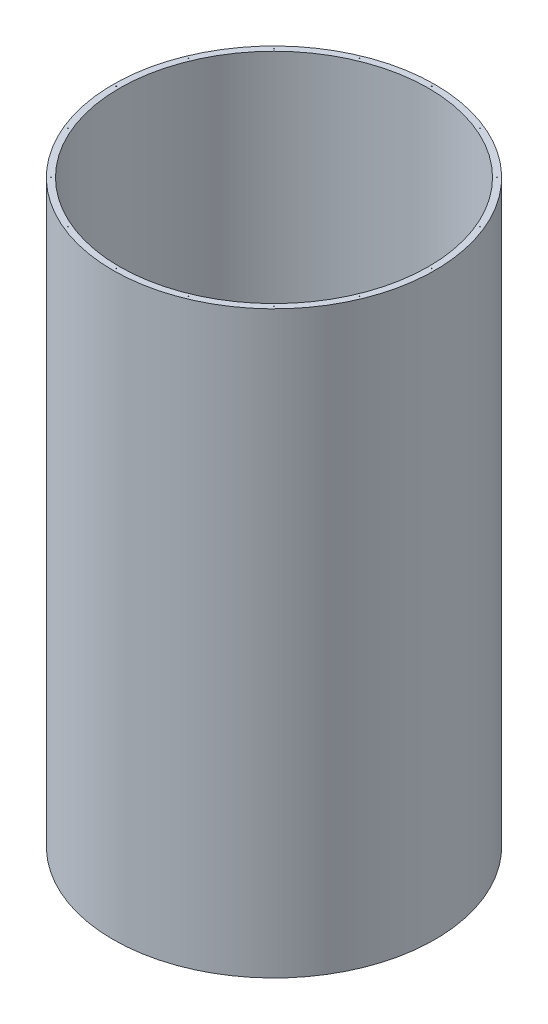
from build123d import *

# Parameters (mm, degrees)
SKETCH1_R           = 1250
SKETCH1_R_2         = 1200.000000046
BOSS_EXTRUDE1_DEPTH = 4500
SKETCH2_R           = 3.175
CUT_EXTRUDE1_DEPTH  = 12.7


with BuildPart() as part:
    # Sketch1 → Boss-Extrude1 (new body)
    with BuildSketch(Plane(origin=(0, 0, 0), x_dir=(1, 0, 0), z_dir=(0, 1, 0))):
        Circle(SKETCH1_R)
        Circle(SKETCH1_R_2, mode=Mode.SUBTRACT)
    extrude(amount=BOSS_EXTRUDE1_DEPTH)

    # Sketch2 → Cut-Extrude1 (cut)
    with BuildSketch(Plane(origin=(0, 4500, 0), x_dir=(1, 0, 0), z_dir=(0, 1, 0))):
        with Locations((-1225, 0)):
            Circle(SKETCH2_R)
        with Locations((-1131.752427326, 468.787204647)):
            Circle(SKETCH2_R)
        with Locations((-866.205806954, 866.205806954)):
            Circle(SKETCH2_R)
        with Locations((-468.787204647, 1131.752427326)):
            Circle(SKETCH2_R)
        with Locations((0, 1225)):
            Circle(SKETCH2_R)
        with Locations((468.787204647, 1131.752427326)):
            Circle(SKETCH2_R)
        with Locations((866.205806954, 866.205806954)):
            Circle(SKETCH2_R)
        with Locations((1131.752427326, 468.787204647)):
            Circle(SKETCH2_R)
        with Locations((1225, 0)):
            Circle(SKETCH2_R)
        with Locations((1131.752427326, -468.787204647)):
            Circle(SKETCH2_R)
        with Locations((866.205806954, -866.205806954)):
            Circle(SKETCH2_R)
        with Locations((468.787204647, -1131.752427326)):
            Circle(SKETCH2_R)
        with Locations((0, -1225)):
            Circle(SKETCH2_R)
        with Locations((-468.787204647, -1131.752427326)):
            Circle(SKETCH2_R)
        with Locations((-866.205806954, -866.205806954)):
            Circle(SKETCH2_R)
        with Locations((-1131.752427326, -468.787204647)):
            Circle(SKETCH2_R)
    extrude(amount=-CUT_EXTRUDE1_DEPTH, mode=Mode.SUBTRACT)


solid = part.part
